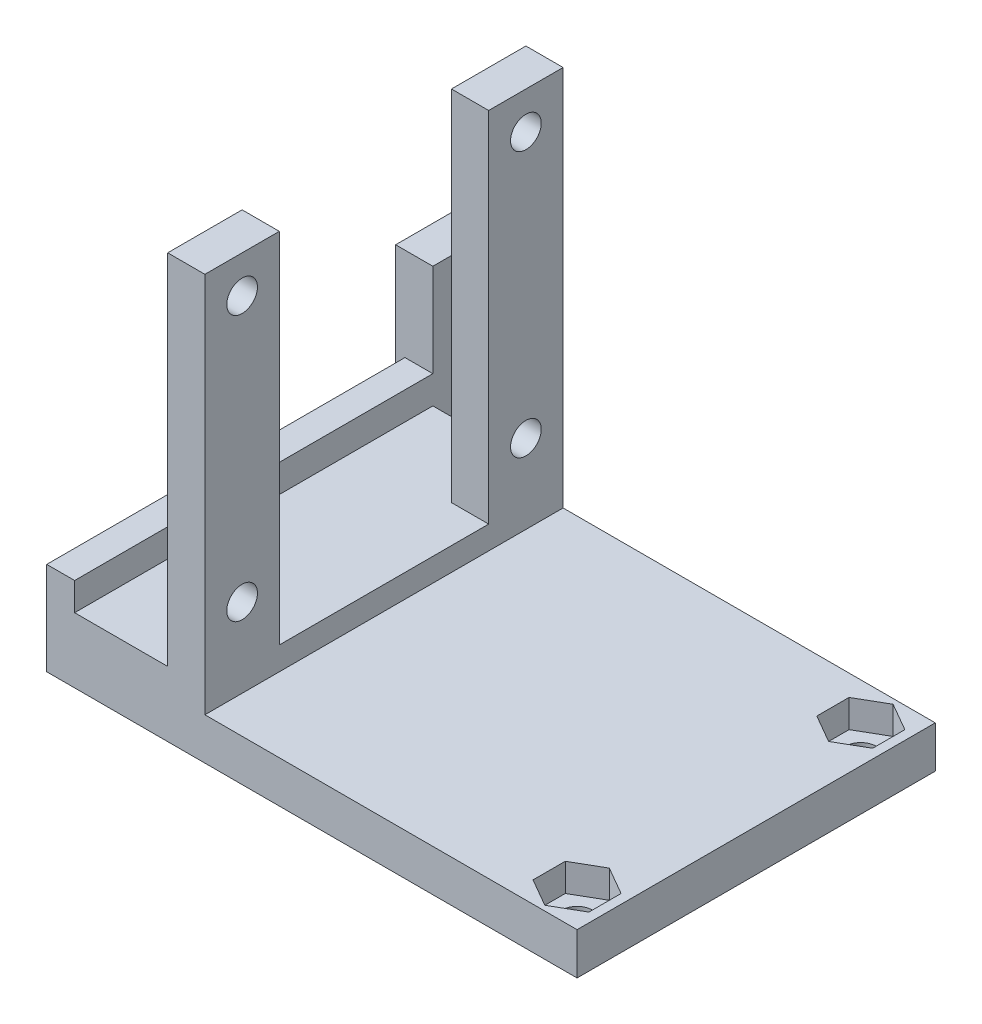
from build123d import *

# Parameters (mm, degrees)
SKETCH1_W                 = 13
SKETCH1_H                 = 16
BOSS_EXTRUDE1_DEPTH       = 4
SKETCH2_R                 = 1.65
CUT_EXTRUDE1_DEPTH        = 10
SKETCH3_W                 = 4
SKETCH3_H                 = 13
BOSS_EXTRUDE2_DEPTH       = 4
SKETCH4_W                 = 13
SKETCH4_H                 = 4
BOSS_EXTRUDE3_DEPTH       = 60
SKETCH6_W                 = 4
SKETCH6_H                 = 21
SKETCH6_H_2               = 13
BOSS_EXTRUDE4_DEPTH       = 28
SKETCH12_W                = 4
SKETCH12_H                = 28
BOSS_EXTRUDE8_DEPTH       = 1.65
SKETCH13_W                = 4
SKETCH13_H                = 28
BOSS_EXTRUDE9_DEPTH       = 1.65
SKETCH14_W                = 4
SKETCH14_H                = 35.878399396
CUT_EXTRUDE5_DEPTH        = 24
SKETCH15_R                = 1.65
CUT_EXTRUDE6_DEPTH        = 24
SKETCH16_W                = 4
SKETCH16_H                = 11.121600604
SKETCH16_H_2              = 11.3
BOSS_EXTRUDE10_DEPTH      = 29.15
SKETCH17_R                = 1.65
CUT_EXTRUDE8_DEPTH        = 29.15
SKETCH18_W                = 22.65
SKETCH18_H                = 4
SKETCH18_W_2              = 13
BOSS_EXTRUDE11_DEPTH      = 4
SKETCH19_W                = 4
SKETCH19_H                = 20
BOSS_EXTRUDE12_DEPTH      = 40
SKETCH20_R                = 1.65
CUT_EXTRUDE9_DEPTH        = 40
SKETCH21_W                = 4
SKETCH21_H                = 30.5
BOSS_EXTRUDE13_DEPTH      = 38.5
SKETCH23_W                = 4
SKETCH23_H                = 4
BOSS_EXTRUDE14_DEPTH      = 38.5
SKETCH24_W                = 4
SKETCH24_H                = 38.5
BOSS_EXTRUDE15_DEPTH      = 3
SKETCH27_W                = 4
SKETCH27_H                = 58.3
CUT_EXTRUDE10_DEPTH       = 100
SKETCH29_W                = 38.5
SKETCH29_H                = 7
BOSS_EXTRUDE16_DEPTH      = 40
BOSS_EXTRUDE16_DEPTH_BACK = 28
SKETCH30_R                = 1.65
CUT_EXTRUDE11_DEPTH       = 40
SKETCH31_W                = 4
SKETCH31_H                = 22.5
CUT_EXTRUDE12_DEPTH       = 38.5
SKETCH32_W                = 38.5
SKETCH32_H                = 2.5
CUT_EXTRUDE13_DEPTH       = 40
SKETCH33_W                = 4
SKETCH33_H                = 8
BOSS_EXTRUDE17_DEPTH      = 8
SKETCH34_R                = 1.65
CUT_EXTRUDE14_DEPTH       = 8
SKETCH35_W                = 4
SKETCH35_H                = 43.5
BOSS_EXTRUDE18_DEPTH      = 13
CUT_EXTRUDE15_START       = -20
SKETCH36_W                = 10
SKETCH36_H                = 80
CUT_EXTRUDE15_DEPTH       = 20
SKETCH37_W                = 5
SKETCH37_H                = 7
BOSS_EXTRUDE19_DEPTH      = 4
SKETCH41_W                = 13
SKETCH41_H                = 20
BOSS_EXTRUDE20_DEPTH      = 4
SKETCH42_R                = 1.65
CUT_EXTRUDE18_DEPTH       = 4
SKETCH43_W                = 4
SKETCH43_H                = 38.5
CUT_EXTRUDE19_DEPTH       = 10
SKETCH44_W                = 8
SKETCH44_H                = 9
BOSS_EXTRUDE21_DEPTH      = 4
SKETCH45_R                = 1.65
CUT_EXTRUDE20_DEPTH       = 4
CUT_EXTRUDE21_DEPTH       = 3
SKETCH49_R                = 1.65
CUT_EXTRUDE22_DEPTH       = 5
SKETCH54_W                = 1
SKETCH54_H                = 38.5
CUT_EXTRUDE24_DEPTH       = 50


with BuildPart() as part:
    # Sketch1 → Boss-Extrude1 (new body)
    with BuildSketch(Plane(origin=(0, 0, 0), x_dir=(0, 0, -1), z_dir=(1, 0, 0))):
        with Locations((6.5, -8)):
            Rectangle(SKETCH1_W, SKETCH1_H)
    extrude(amount=BOSS_EXTRUDE1_DEPTH)

    # Sketch2 → Cut-Extrude1 (cut)
    with BuildSketch(Plane(origin=(4, 0, 0), x_dir=(0, 0, -1), z_dir=(1, 0, 0))):
        with Locations((6.5, -4)):
            Circle(SKETCH2_R)
        with Locations((6.5, -12)):
            Circle(SKETCH2_R)
    extrude(amount=-CUT_EXTRUDE1_DEPTH, mode=Mode.SUBTRACT)

    # Sketch3 → Boss-Extrude2 (add)
    with BuildSketch(Plane.XZ.offset(16)):
        with Locations((2, -6.5)):
            Rectangle(SKETCH3_W, SKETCH3_H)
    extrude(amount=BOSS_EXTRUDE2_DEPTH)

    # Sketch4 → Boss-Extrude3 (add)
    with BuildSketch(Plane(origin=(4, 0, 0), x_dir=(0, 0, -1), z_dir=(1, 0, 0))):
        with Locations((6.5, -18)):
            Rectangle(SKETCH4_W, SKETCH4_H)
    extrude(amount=BOSS_EXTRUDE3_DEPTH)

    # Sketch6 → Boss-Extrude4 (add)
    with BuildSketch(Plane(origin=(0, -16, 0), x_dir=(1, 0, 0), z_dir=(0, 1, 0))):
        with Locations((62, -10.5)):
            Rectangle(SKETCH6_W, SKETCH6_H)
        with Locations((62, 23.5)):
            Rectangle(SKETCH6_W, SKETCH6_H)
        with Locations((62, 6.5)):
            Rectangle(SKETCH6_W, SKETCH6_H_2)
    extrude(amount=BOSS_EXTRUDE4_DEPTH)

    # Sketch12 → Boss-Extrude8 (add)
    with BuildSketch(Plane(origin=(0, 0, -34), x_dir=(-1, 0, 0), z_dir=(0, 0, -1))):
        with Locations((-62, -2)):
            Rectangle(SKETCH12_W, SKETCH12_H)
    extrude(amount=BOSS_EXTRUDE8_DEPTH)

    # Sketch13 → Boss-Extrude9 (add)
    with BuildSketch(Plane.XY.offset(21)):
        with Locations((62, -2)):
            Rectangle(SKETCH13_W, SKETCH13_H)
    extrude(amount=BOSS_EXTRUDE9_DEPTH)

    # Sketch14 → Cut-Extrude5 (cut)
    with BuildSketch(Plane(origin=(0, 12, 0), x_dir=(1, 0, 0), z_dir=(0, 1, 0))):
        with Locations((62, 6.410800302)):
            Rectangle(SKETCH14_W, SKETCH14_H)
    extrude(amount=-CUT_EXTRUDE5_DEPTH, mode=Mode.SUBTRACT)

    # Sketch15 → Cut-Extrude6 (cut)
    with BuildSketch(Plane(origin=(64, 0, 0), x_dir=(0, 0, -1), z_dir=(1, 0, 0))):
        with Locations((-17, -11.5)):
            Circle(SKETCH15_R)
        with Locations((30, -11.5)):
            Circle(SKETCH15_R)
    extrude(amount=-CUT_EXTRUDE6_DEPTH, mode=Mode.SUBTRACT)

    # Sketch16 → Boss-Extrude10 (add)
    with BuildSketch(Plane(origin=(0, 12, 0), x_dir=(1, 0, 0), z_dir=(0, 1, 0))):
        with Locations((62, -17.089199698)):
            Rectangle(SKETCH16_W, SKETCH16_H)
        with Locations((62, 30)):
            Rectangle(SKETCH16_W, SKETCH16_H_2)
    extrude(amount=BOSS_EXTRUDE10_DEPTH)

    # Sketch17 → Cut-Extrude8 (cut)
    with BuildSketch(Plane(origin=(64, 0, 0), x_dir=(0, 0, -1), z_dir=(1, 0, 0))):
        with Locations((-17, 35.5)):
            Circle(SKETCH17_R)
        with Locations((30, 35.5)):
            Circle(SKETCH17_R)
    extrude(amount=-CUT_EXTRUDE8_DEPTH, mode=Mode.SUBTRACT)

    # Sketch18 → Boss-Extrude11 (add)
    with BuildSketch(Plane(origin=(64, 0, 0), x_dir=(0, 0, -1), z_dir=(1, 0, 0))):
        with Locations((-11.325, -18)):
            Rectangle(SKETCH18_W, SKETCH18_H)
        with Locations((24.325, -18)):
            Rectangle(SKETCH18_W, SKETCH18_H)
        with Locations((6.5, -18)):
            Rectangle(SKETCH18_W_2, SKETCH18_H)
    extrude(amount=-BOSS_EXTRUDE11_DEPTH)

    # Sketch19 → Boss-Extrude12 (add)
    with BuildSketch(Plane(origin=(0, 0, -13), x_dir=(-1, 0, 0), z_dir=(0, 0, -1))):
        with Locations((-2, -10)):
            Rectangle(SKETCH19_W, SKETCH19_H)
    extrude(amount=BOSS_EXTRUDE12_DEPTH)

    # Sketch20 → Cut-Extrude9 (cut)
    with BuildSketch(Plane.ZY):
        with Locations((-46.5, -4)):
            Circle(SKETCH20_R)
        with Locations((-46.5, -12)):
            Circle(SKETCH20_R)
    extrude(amount=-CUT_EXTRUDE9_DEPTH, mode=Mode.SUBTRACT)

    # Sketch21 → Boss-Extrude13 (add)
    with BuildSketch(Plane(origin=(0, -16, 0), x_dir=(1, 0, 0), z_dir=(0, 1, 0))):
        with Locations((26, 6.5)):
            Rectangle(SKETCH21_W, SKETCH21_H)
    extrude(amount=BOSS_EXTRUDE13_DEPTH)

    # Sketch23 → Boss-Extrude14 (add)
    with BuildSketch(Plane(origin=(0, 22.5, 0), x_dir=(1, 0, 0), z_dir=(0, 1, 0))):
        with Locations((26, 23.75)):
            Rectangle(SKETCH23_W, SKETCH23_H)
        with Locations((26, -10.75)):
            Rectangle(SKETCH23_W, SKETCH23_H)
    extrude(amount=-BOSS_EXTRUDE14_DEPTH)

    # Sketch24 → Boss-Extrude15 (add)
    with BuildSketch(Plane(origin=(0, 22.5, 0), x_dir=(1, 0, 0), z_dir=(0, 1, 0))):
        with Locations((26, 6.5)):
            Rectangle(SKETCH24_W, SKETCH24_H)
    extrude(amount=BOSS_EXTRUDE15_DEPTH)

    # Sketch27 → Cut-Extrude10 (cut)
    with BuildSketch(Plane.XZ.offset(20)):
        with Locations((62, -6.5)):
            Rectangle(SKETCH27_W, SKETCH27_H)
    extrude(amount=-CUT_EXTRUDE10_DEPTH, mode=Mode.SUBTRACT)

    # Sketch29 → Boss-Extrude16 (add, two sides)
    with BuildSketch(Plane(origin=(28, 0, 0), x_dir=(0, 0, -1), z_dir=(1, 0, 0))) as boss_extrude16_sk:
        with Locations((6.5, -16.5)):
            Rectangle(SKETCH29_W, SKETCH29_H)
    extrude(amount=BOSS_EXTRUDE16_DEPTH)
    extrude(boss_extrude16_sk.sketch, amount=-BOSS_EXTRUDE16_DEPTH_BACK)

    # Sketch30 → Cut-Extrude11 (cut)
    with BuildSketch(Plane.ZY.offset(-24)):
        with Locations((8.75, 21.5)):
            Circle(SKETCH30_R)
        with Locations((8.75, -9)):
            Circle(SKETCH30_R)
        with Locations((-21.75, 21.5)):
            Circle(SKETCH30_R)
        with Locations((-21.75, -9)):
            Circle(SKETCH30_R)
    extrude(amount=-CUT_EXTRUDE11_DEPTH, mode=Mode.SUBTRACT)

    # Sketch31 → Cut-Extrude12 (cut)
    with BuildSketch(Plane(origin=(0, 25.5, 0), x_dir=(1, 0, 0), z_dir=(0, 1, 0))):
        with Locations((26, 6.5)):
            Rectangle(SKETCH31_W, SKETCH31_H)
    extrude(amount=-CUT_EXTRUDE12_DEPTH, mode=Mode.SUBTRACT)

    # Sketch32 → Cut-Extrude13 (cut)
    with BuildSketch(Plane(origin=(68, 0, 0), x_dir=(0, 0, -1), z_dir=(1, 0, 0))):
        with Locations((6.5, -14.25)):
            Rectangle(SKETCH32_W, SKETCH32_H)
    extrude(amount=-CUT_EXTRUDE13_DEPTH, mode=Mode.SUBTRACT)

    # Sketch33 → Boss-Extrude17 (add)
    with BuildSketch(Plane(origin=(0, 25.5, 0), x_dir=(1, 0, 0), z_dir=(0, 1, 0))):
        with Locations((26, -8.75)):
            Rectangle(SKETCH33_W, SKETCH33_H)
        with Locations((26, 21.75)):
            Rectangle(SKETCH33_W, SKETCH33_H)
    extrude(amount=-BOSS_EXTRUDE17_DEPTH)

    # Sketch34 → Cut-Extrude14 (cut)
    with BuildSketch(Plane(origin=(28, 0, 0), x_dir=(0, 0, -1), z_dir=(1, 0, 0))):
        with Locations((-8.75, 21.5)):
            Circle(SKETCH34_R)
        with Locations((21.75, 21.5)):
            Circle(SKETCH34_R)
    extrude(amount=-CUT_EXTRUDE14_DEPTH, mode=Mode.SUBTRACT)

    # Sketch35 → Boss-Extrude18 (add)
    with BuildSketch(Plane(origin=(0, -13, 0), x_dir=(1, 0, 0), z_dir=(0, 1, 0))):
        with Locations((12, 9)):
            Rectangle(SKETCH35_W, SKETCH35_H)
    extrude(amount=BOSS_EXTRUDE18_DEPTH)

    # Sketch36 → Cut-Extrude15 (cut)
    with BuildSketch(Plane.XZ.offset(20).offset(CUT_EXTRUDE15_START)):
        with Locations((5, -27.25)):
            Rectangle(SKETCH36_W, SKETCH36_H)
    extrude(amount=CUT_EXTRUDE15_DEPTH, mode=Mode.SUBTRACT)

    # Sketch37 → Boss-Extrude19 (add)
    with BuildSketch(Plane.ZY.offset(-10)):
        with Locations((-28.25, -16.5)):
            Rectangle(SKETCH37_W, SKETCH37_H)
    extrude(amount=-BOSS_EXTRUDE19_DEPTH)

    # Sketch41 → Boss-Extrude20 (add)
    with BuildSketch(Plane(origin=(14, 0, 0), x_dir=(0, 0, -1), z_dir=(1, 0, 0))):
        with Locations((32.25, -10)):
            Rectangle(SKETCH41_W, SKETCH41_H)
    extrude(amount=-BOSS_EXTRUDE20_DEPTH)

    # Sketch42 → Cut-Extrude18 (cut)
    with BuildSketch(Plane.ZY.offset(-10)):
        with Locations((-32.25, -4)):
            Circle(SKETCH42_R)
        with Locations((-32.25, -12)):
            Circle(SKETCH42_R)
    extrude(amount=-CUT_EXTRUDE18_DEPTH, mode=Mode.SUBTRACT)

    # Sketch43 → Cut-Extrude19 (cut)
    with BuildSketch(Plane(origin=(0, 0, 0), x_dir=(1, 0, 0), z_dir=(0, 1, 0))):
        with Locations((12, 6.5)):
            Rectangle(SKETCH43_W, SKETCH43_H)
    extrude(amount=-CUT_EXTRUDE19_DEPTH, mode=Mode.SUBTRACT)

    # Sketch44 → Boss-Extrude21 (add)
    with BuildSketch(Plane(origin=(28, 0, 0), x_dir=(0, 0, -1), z_dir=(1, 0, 0))):
        with Locations((-8.75, -11)):
            Rectangle(SKETCH44_W, SKETCH44_H)
        with Locations((21.75, -11)):
            Rectangle(SKETCH44_W, SKETCH44_H)
    extrude(amount=-BOSS_EXTRUDE21_DEPTH)

    # Sketch45 → Cut-Extrude20 (cut)
    with BuildSketch(Plane.ZY.offset(-24)):
        with Locations((-21.75, -7)):
            Circle(SKETCH45_R)
        with Locations((8.75, -7)):
            Circle(SKETCH45_R)
    extrude(amount=-CUT_EXTRUDE20_DEPTH, mode=Mode.SUBTRACT)

    # Sketch46 → Cut-Extrude21 (cut)
    with BuildSketch(Plane(origin=(0, -15.5, 0), x_dir=(1, 0, 0), z_dir=(0, 1, 0))):
        Polygon((64, 18.285898385), (67, 20.017949192), (67, 23.482050808), (64, 25.214101615), (61, 23.482050808), (61, 20.017949192), align=None)
        Polygon((64, -12.214101615), (67, -10.482050808), (67, -7.017949192), (64, -5.285898385), (61, -7.017949192), (61, -10.482050808), align=None)
    extrude(amount=-CUT_EXTRUDE21_DEPTH, mode=Mode.SUBTRACT)

    # Sketch49 → Cut-Extrude22 (cut)
    with BuildSketch(Plane(origin=(0, -15.5, 0), x_dir=(1, 0, 0), z_dir=(0, 1, 0))):
        with Locations((64, 21.75)):
            Circle(SKETCH49_R)
        with Locations((64, -8.75)):
            Circle(SKETCH49_R)
    extrude(amount=-CUT_EXTRUDE22_DEPTH, mode=Mode.SUBTRACT)

    # Sketch54 → Cut-Extrude24 (cut)
    with BuildSketch(Plane(origin=(0, -10, 0), x_dir=(1, 0, 0), z_dir=(0, 1, 0))):
        with Locations((10.5, 6.5)):
            Rectangle(SKETCH54_W, SKETCH54_H)
    extrude(amount=-CUT_EXTRUDE24_DEPTH, mode=Mode.SUBTRACT)


solid = part.part
